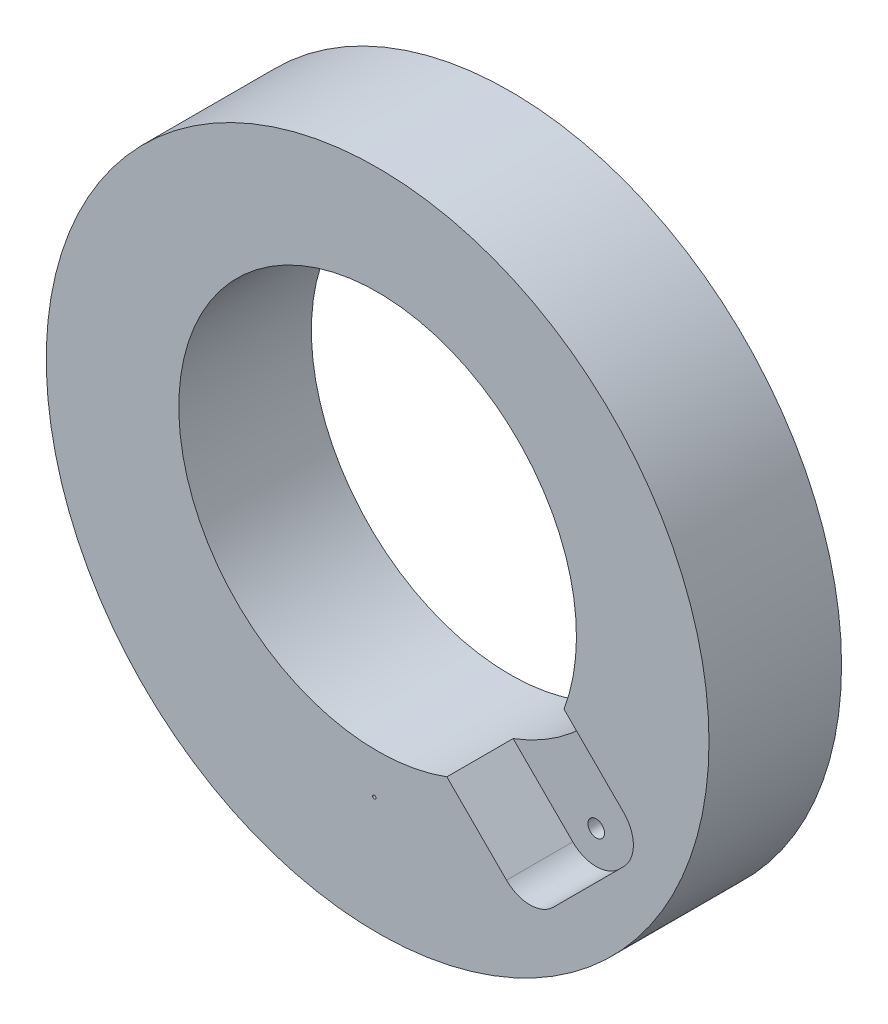
from build123d import *

# Parameters (mm, degrees)
SKIZZE1_R                       = 100
SKIZZE1_R_2                     = 60
BASIS_LINEAR_AUSTRAGEN_DEPTH    = 40
SCHNITT_LINEAR_AUSTRAGEN1_DEPTH = 20
SKIZZE4_R                       = 0.5
SCHNITT_LINEAR_AUSTRAGEN3_DEPTH = 41
M6X1_0_GEWINDEKERNLOCH1_D       = 5


with BuildPart() as part:
    # Skizze1 → Basis-Linear austragen (new body)
    with BuildSketch(Plane.XY):
        Circle(SKIZZE1_R)
        with Locations((0, 7.5)):
            Circle(SKIZZE1_R_2, mode=Mode.SUBTRACT)
    extrude(amount=BASIS_LINEAR_AUSTRAGEN_DEPTH)

    # Skizze2 → Schnitt-Linear austragen1 (cut)
    with BuildSketch(Plane.XY.offset(40)):
        with BuildLine():
            Line((17.272249399, -45.127588459), (52.627588459, -9.772249399))
            Line((52.627588459, -9.772249399), (74.246212025, -31.390872965))
            ThreePointArc((74.246212025, -31.390872965), (77.175144213, -38.461940777), (74.246212025, -45.533008589))
            Line((74.246212025, -45.533008589), (53.033008589, -66.746212025))
            ThreePointArc((53.033008589, -66.746212025), (45.961940777, -69.675144213), (38.890872965, -66.746212025))
            Line((38.890872965, -66.746212025), (17.272249399, -45.127588459))
        make_face()
    extrude(amount=-SCHNITT_LINEAR_AUSTRAGEN1_DEPTH, mode=Mode.SUBTRACT)

    # Skizze4 → Schnitt-Linear austragen3 (cut, through all)
    with BuildSketch(Plane.XY.offset(40)):
        with Locations((-1, -64.992307237)):
            Circle(SKIZZE4_R)
    extrude(amount=-SCHNITT_LINEAR_AUSTRAGEN3_DEPTH, mode=Mode.SUBTRACT)

    # M6x1.0 Gewindekernloch1 (through all)
    with Locations(Plane.XY.offset(20)):
        with Locations((45.961940777, -59.675144213), (67.175144213, -38.461940777)):
            Hole(M6X1_0_GEWINDEKERNLOCH1_D / 2)


solid = part.part
